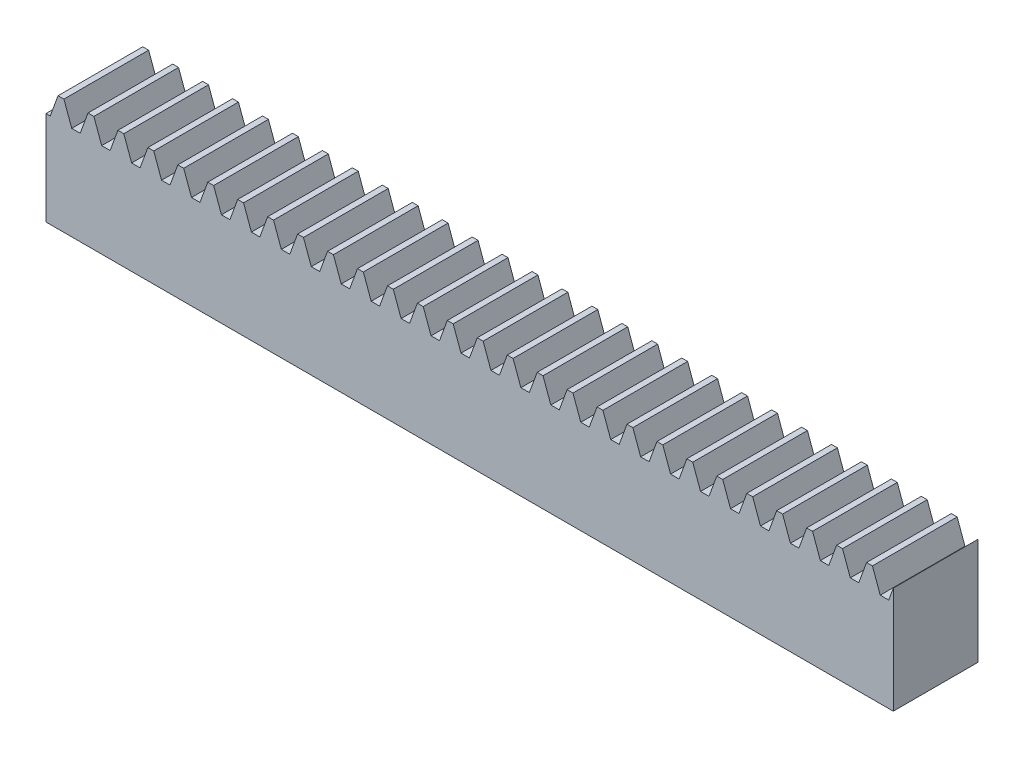
from build123d import *

# Parameters (mm, degrees)
BLANKSKE_W        = 80
BLANKSKE_H        = 10.9
BLANK_DEPTH       = 8
TOOTHCUTSIM_DEPTH = 82.134517932
TEETHCUTS_COUNT   = 29
TEETHCUTS_PITCH   = 2.827433385


with BuildPart() as part:
    # BlankSke → Blank (new body)
    with BuildSketch(Plane.XY):
        with Locations((40, 5.45)):
            Rectangle(BLANKSKE_W, BLANKSKE_H)
    extrude(amount=-BLANK_DEPTH)

    # TooCutSkeSim → ToothCutSim (cut, through all)
    with BuildSketch(Plane.XY):
        Polygon((0.399391833, 8.875), (-0.399391833, 8.875), (-1.145676401, 10.9254), (1.145676401, 10.9254), align=None)
    toothcutsim = extrude(amount=-TOOTHCUTSIM_DEPTH, mode=Mode.SUBTRACT)

    # TeethCuts: ToothCutSim ×29
    with Locations(*[(i * TEETHCUTS_PITCH, 0, 0) for i in range(1, TEETHCUTS_COUNT)]):
        add(toothcutsim, mode=Mode.SUBTRACT)


solid = part.part
